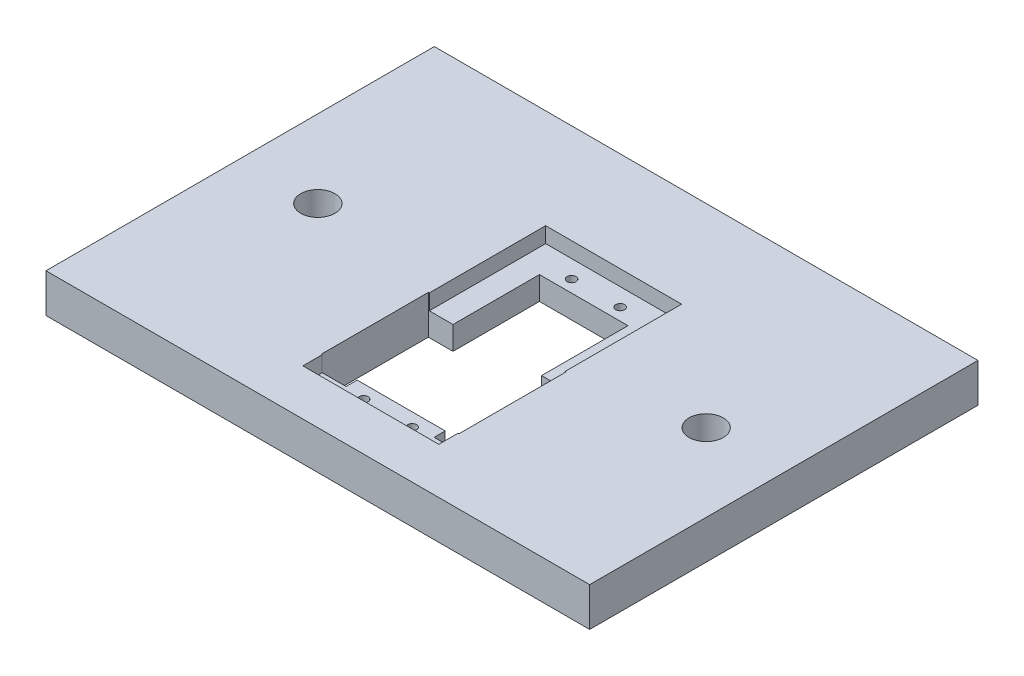
from build123d import *

# Parameters (mm, degrees)
SKETCH1_W           = 177.8
SKETCH1_H           = 127
SKETCH1_R           = 5.588
SKETCH1_R_2         = 1.4605
SKETCH1_W_2         = 28.956
SKETCH1_H_2         = 59.69
BOSS_EXTRUDE1_DEPTH = 12.7
SKETCH3_W           = 8.128
SKETCH3_H           = 35.052
CUT_EXTRUDE3_DEPTH  = 13.7
SKETCH2_W           = 44.45
SKETCH2_H           = 79.4004
CUT_EXTRUDE4_DEPTH  = 5.08


with BuildPart() as part:
    # Sketch1 → Boss-Extrude1 (new body)
    with BuildSketch(Plane(origin=(0, 0, 0), x_dir=(1, 0, 0), z_dir=(0, 1, 0))):
        Rectangle(SKETCH1_W, SKETCH1_H)
        with Locations((-63.5, 0)):
            Circle(SKETCH1_R, mode=Mode.SUBTRACT)
        with Locations((63.5, 0)):
            Circle(SKETCH1_R, mode=Mode.SUBTRACT)
        with Locations((-5.667565537, -42.871775783)):
            Circle(SKETCH1_R_2, mode=Mode.SUBTRACT)
        with Locations((10.207434463, -42.871775783)):
            Circle(SKETCH1_R_2, mode=Mode.SUBTRACT)
        with Locations((-5.667565537, 25.149424217)):
            Circle(SKETCH1_R_2, mode=Mode.SUBTRACT)
        with Locations((10.207434463, 25.149424217)):
            Circle(SKETCH1_R_2, mode=Mode.SUBTRACT)
        with Locations((2.269934463, -8.661150783)):
            Rectangle(SKETCH1_W_2, SKETCH1_H_2, mode=Mode.SUBTRACT)
    extrude(amount=BOSS_EXTRUDE1_DEPTH)

    # Sketch3 → Cut-Extrude3 (cut, through all)
    with BuildSketch(Plane(origin=(0, 0, 0), x_dir=(1, 0, 0), z_dir=(0, 1, 0))):
        with Locations((-16.19114245, -24.615525783)):
            Rectangle(SKETCH3_W, SKETCH3_H)
        with Locations((20.731011375, -24.615525783)):
            Rectangle(SKETCH3_W, SKETCH3_H)
    extrude(amount=CUT_EXTRUDE3_DEPTH, mode=Mode.SUBTRACT)

    # Sketch2 → Cut-Extrude4 (cut)
    with BuildSketch(Plane(origin=(0, 12.7, 0), x_dir=(1, 0, 0), z_dir=(0, 1, 0))):
        with Locations((2.269934463, -8.737350783)):
            Rectangle(SKETCH2_W, SKETCH2_H)
    extrude(amount=-CUT_EXTRUDE4_DEPTH, mode=Mode.SUBTRACT)


solid = part.part
